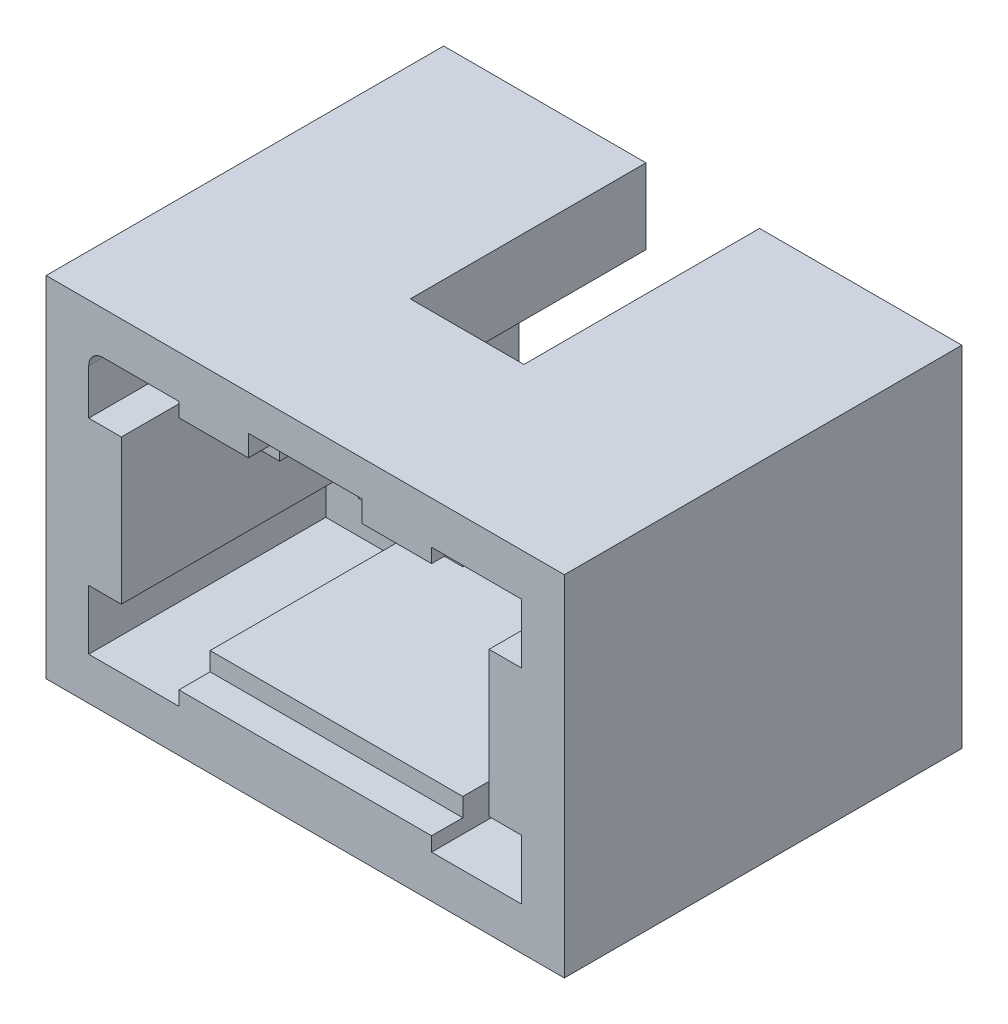
from build123d import *

# Parameters (mm, degrees)
SKETCH1_W               = 18.25
SKETCH1_H               = 12.3
SKETCH1_W_2             = 14.25
SKETCH1_H_2             = 8.3
BOSS_EXTRUDE1_DEPTH     = 14
SKETCH4_W               = 8.9
SKETCH4_H               = 0.65
BOSS_EXTRUDE2_DEPTH     = 12.9
SKETCH4_3_W             = 0.65
SKETCH4_3_H             = 5.1
BOSS_EXTRUDE3_DEPTH     = 14
SKETCH5_W               = 4
SKETCH5_H               = 2.65
CUT_EXTRUDE2_DEPTH      = 8.3
BOSS_EXTRUDE4_DEPTH     = 5.65
SKETCH7_W               = 4
SKETCH7_H               = 1.4
CUT_EXTRUDE3_DEPTH      = 6.7
SKETCH8_R               = 0.5
CUT_EXTRUDE4_DEPTH      = 8.35
MIRROR2_COPY_1_SKETCH_R = 0.5
MIRROR2_COPY_1_DEPTH    = 8.35
CUT_EXTRUDE5_DEPTH      = 8.35


with BuildPart() as part:
    # Sketch1 → Boss-Extrude1 (new body)
    with BuildSketch(Plane.XY):
        Rectangle(SKETCH1_W, SKETCH1_H)
        Rectangle(SKETCH1_W_2, SKETCH1_H_2, mode=Mode.SUBTRACT)
    extrude(amount=BOSS_EXTRUDE1_DEPTH)

    # Sketch4 → Boss-Extrude2 (add)
    with BuildSketch(Plane(origin=(0, 0, 0), x_dir=(-1, 0, 0), z_dir=(0, 0, -1))):
        with Locations((0, 3.825)):
            Rectangle(SKETCH4_W, SKETCH4_H)
        with Locations((0, -3.825)):
            Rectangle(SKETCH4_W, SKETCH4_H)
    extrude(amount=-BOSS_EXTRUDE2_DEPTH)

    # Sketch4_3 → Boss-Extrude3 (add)
    with BuildSketch(Plane(origin=(0, 0, 0), x_dir=(-1, 0, 0), z_dir=(0, 0, -1))):
        with Locations((-6.8, 0)):
            Rectangle(SKETCH4_3_W, SKETCH4_3_H)
        with Locations((6.8, 0)):
            Rectangle(SKETCH4_3_W, SKETCH4_3_H)
    extrude(amount=-BOSS_EXTRUDE3_DEPTH)

    # Sketch5 → Cut-Extrude2 (cut)
    with BuildSketch(Plane(origin=(0, 0, 0), x_dir=(-1, 0, 0), z_dir=(0, 0, -1))):
        with Locations((0, 4.825)):
            Rectangle(SKETCH5_W, SKETCH5_H)
    extrude(amount=-CUT_EXTRUDE2_DEPTH, mode=Mode.SUBTRACT)

    # Sketch6 → Boss-Extrude4 (add)
    with BuildSketch(Plane(origin=(0, 0, 0), x_dir=(-1, 0, 0), z_dir=(0, 0, -1))):
        Polygon((6.475, -3.5), (4.45, -3.5), (4.45, -4.15), (7.125, -4.15), (7.125, -2.55), (6.475, -2.55), align=None)
        Polygon((6.475, 3.5), (6.475, 2.55), (7.125, 2.55), (7.125, 4.15), (4.45, 4.15), (4.45, 3.5), align=None)
        Polygon((-7.125, 2.55), (-6.475, 2.55), (-6.475, 3.5), (-4.45, 3.5), (-4.45, 4.15), (-7.125, 4.15), align=None)
        Polygon((-4.45, -4.15), (-4.45, -3.5), (-6.475, -3.5), (-6.475, -2.55), (-7.125, -2.55), (-7.125, -4.15), align=None)
    extrude(amount=-BOSS_EXTRUDE4_DEPTH)

    # Sketch7 → Cut-Extrude3 (cut, through all)
    with BuildSketch(Plane(origin=(0, 0, 8.3), x_dir=(-1, 0, 0), z_dir=(0, 0, -1))):
        with Locations((0, 4.2)):
            Rectangle(SKETCH7_W, SKETCH7_H)
    extrude(amount=-CUT_EXTRUDE3_DEPTH, mode=Mode.SUBTRACT)

    # Sketch8 → Cut-Extrude4 (cut)
    with BuildSketch(Plane.XY.offset(14)):
        with Locations((-7.125, 4.15)):
            Circle(SKETCH8_R)
    cut_extrude4 = extrude(amount=-CUT_EXTRUDE4_DEPTH, mode=Mode.SUBTRACT)

    # Mirror1: Cut-Extrude4 across plane
    add(cut_extrude4.mirror(Plane.ZX), mode=Mode.SUBTRACT)

    # Mirror2: Cut-Extrude4 across plane
    add(cut_extrude4.mirror(Plane(origin=(0, 0, 0), x_dir=(0, 0, 1), z_dir=(1, 0, 0))), mode=Mode.SUBTRACT)

    # Mirror2 copy 1 sketch → Mirror2 copy 1 (cut)
    with BuildSketch(Plane(origin=(0, 0, 14), x_dir=(-1, 0, 0), z_dir=(0, 0, 1))):
        with Locations((-7.125, 4.15)):
            Circle(MIRROR2_COPY_1_SKETCH_R)
    extrude(amount=-MIRROR2_COPY_1_DEPTH, mode=Mode.SUBTRACT)

    # Sketch9 → Cut-Extrude5 (cut)
    with BuildSketch(Plane.XY.offset(14)):
        with BuildLine():
            ThreePointArc((-7.625, -4.15), (-7.478553391, -4.503553391), (-7.125, -4.65))
            ThreePointArc((-7.125, -4.65), (-6.771446609, -4.503553391), (-6.625, -4.15))
            Line((-6.625, -4.15), (-4.45, -4.15))
            Line((-4.45, -4.15), (-4.45, -2.55))
            Line((-4.45, -2.55), (-6.475, -2.55))
            Line((-6.475, -2.55), (-7.125, -2.55))
            Line((-7.125, -2.55), (-7.125, -3.65))
            ThreePointArc((-7.125, -3.65), (-7.478553391, -3.796446609), (-7.625, -4.15))
        make_face()
        with BuildLine():
            ThreePointArc((-6.625, -4.15), (-6.771446609, -4.503553391), (-7.125, -4.65))
            Line((-7.125, -4.65), (-4.45, -4.65))
            Line((-4.45, -4.65), (-4.45, -4.15))
            Line((-4.45, -4.15), (-6.625, -4.15))
        make_face()
        with BuildLine():
            Line((-7.625, -2.55), (-7.625, -4.15))
            ThreePointArc((-7.625, -4.15), (-7.478553391, -3.796446609), (-7.125, -3.65))
            Line((-7.125, -3.65), (-7.125, -2.55))
            Line((-7.125, -2.55), (-7.625, -2.55))
        make_face()
        with BuildLine():
            Line((-7.625, 4.15), (-7.625, 2.55))
            Line((-7.625, 2.55), (-7.125, 2.55))
            Line((-7.125, 2.55), (-7.125, 3.65))
            ThreePointArc((-7.125, 3.65), (-7.478553391, 3.796446609), (-7.625, 4.15))
        make_face()
        with BuildLine():
            Line((-4.45, 4.65), (-7.125, 4.65))
            ThreePointArc((-7.125, 4.65), (-6.771446609, 4.503553391), (-6.625, 4.15))
            Line((-6.625, 4.15), (-4.45, 4.15))
            Line((-4.45, 4.15), (-4.45, 4.65))
        make_face()
        with BuildLine():
            ThreePointArc((7.125, -3.65), (7.478553391, -3.796446609), (7.625, -4.15))
            Line((7.625, -4.15), (7.625, -2.55))
            Line((7.625, -2.55), (7.125, -2.55))
            Line((7.125, -2.55), (7.125, -3.65))
        make_face()
        with BuildLine():
            Line((6.625, -4.15), (4.45, -4.15))
            Line((4.45, -4.15), (4.45, -4.65))
            Line((4.45, -4.65), (7.125, -4.65))
            ThreePointArc((7.125, -4.65), (6.771446609, -4.503553391), (6.625, -4.15))
        make_face()
        with BuildLine():
            Line((4.45, -2.55), (4.45, -4.15))
            Line((4.45, -4.15), (6.625, -4.15))
            ThreePointArc((6.625, -4.15), (6.771446609, -4.503553391), (7.125, -4.65))
            ThreePointArc((7.125, -4.65), (7.478553391, -4.503553391), (7.625, -4.15))
            ThreePointArc((7.625, -4.15), (7.478553391, -3.796446609), (7.125, -3.65))
            Line((7.125, -3.65), (7.125, -2.55))
            Line((7.125, -2.55), (6.475, -2.55))
            Line((6.475, -2.55), (4.45, -2.55))
        make_face()
        with BuildLine():
            ThreePointArc((7.625, -4.15), (7.478553391, -4.503553391), (7.125, -4.65))
            Line((7.125, -4.65), (7.625, -4.65))
            Line((7.625, -4.65), (7.625, -4.15))
        make_face()
        with BuildLine():
            Line((7.625, 4.65), (7.125, 4.65))
            ThreePointArc((7.125, 4.65), (7.478553391, 4.503553391), (7.625, 4.15))
            Line((7.625, 4.15), (7.625, 4.65))
        make_face()
        with BuildLine():
            Line((7.625, 2.55), (7.625, 4.15))
            ThreePointArc((7.625, 4.15), (7.478553391, 3.796446609), (7.125, 3.65))
            Line((7.125, 3.65), (7.125, 2.55))
            Line((7.125, 2.55), (7.625, 2.55))
        make_face()
        with BuildLine():
            Line((7.125, 4.65), (4.45, 4.65))
            Line((4.45, 4.65), (4.45, 4.15))
            Line((4.45, 4.15), (6.625, 4.15))
            ThreePointArc((6.625, 4.15), (6.771446609, 4.503553391), (7.125, 4.65))
        make_face()
        with BuildLine():
            Line((6.625, 4.15), (4.45, 4.15))
            Line((4.45, 4.15), (4.45, 2.55))
            Line((4.45, 2.55), (6.475, 2.55))
            Line((6.475, 2.55), (7.125, 2.55))
            Line((7.125, 2.55), (7.125, 3.65))
            ThreePointArc((7.125, 3.65), (7.478553391, 3.796446609), (7.625, 4.15))
            ThreePointArc((7.625, 4.15), (7.478553391, 4.503553391), (7.125, 4.65))
            ThreePointArc((7.125, 4.65), (6.771446609, 4.503553391), (6.625, 4.15))
        make_face()
        with BuildLine():
            Line((-7.625, -4.15), (-7.625, -4.65))
            Line((-7.625, -4.65), (-7.125, -4.65))
            ThreePointArc((-7.125, -4.65), (-7.478553391, -4.503553391), (-7.625, -4.15))
        make_face()
    extrude(amount=-CUT_EXTRUDE5_DEPTH, mode=Mode.SUBTRACT)


solid = part.part
